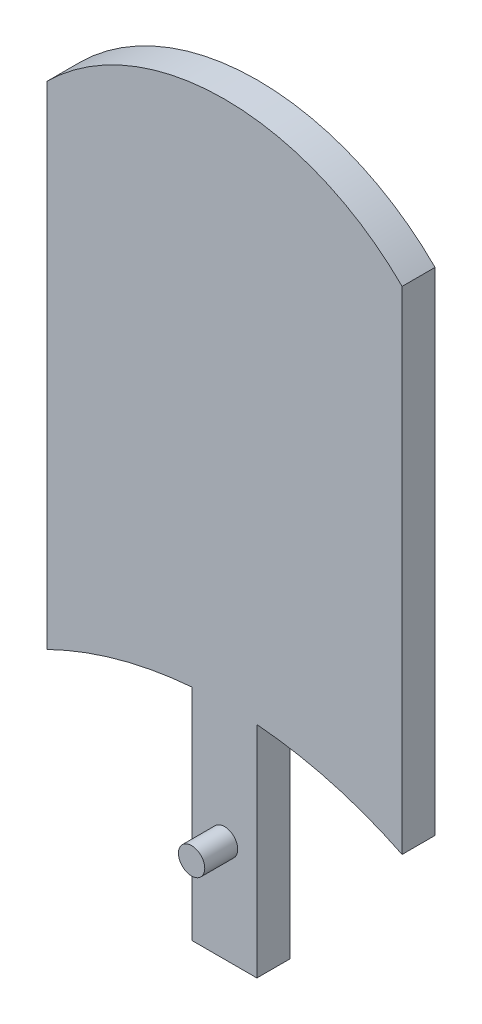
from build123d import *

# Parameters (mm, degrees)
BOSS_EXTRUDE1_DEPTH = 3.175
BOSS_EXTRUDE2_DEPTH = 3.175
SKETCH3_W           = 6.236959702
SKETCH3_H           = 41.352711554
BOSS_EXTRUDE3_DEPTH = 3.175
SKETCH4_R           = 1.27
BOSS_EXTRUDE4_DEPTH = 3.175
BOSS_EXTRUDE5_REACH = 20.766
SKETCH6_W           = 1.202138058
SKETCH6_H           = 43.066281197
CUT_EXTRUDE1_REACH  = 11.525


with BuildPart() as part:
    # Sketch1 → Boss-Extrude1 (new body)
    with BuildSketch(Plane.XY):
        with BuildLine():
            Line((-17.114253333, -23.707583903), (-17.114253333, 23.707583903))
            ThreePointArc((-17.114253333, 23.707583903), (0, 30.782200079), (17.114253333, 23.707583903))
            Line((17.114253333, 23.707583903), (17.114253333, -23.707583903))
            ThreePointArc((17.114253333, -23.707583903), (0, -19.732802645), (-17.114253333, -23.707583903))
        make_face()
    extrude(amount=BOSS_EXTRUDE1_DEPTH)

    # Sketch2 → Boss-Extrude2 (add)
    with BuildSketch(Plane(origin=(0, 0, 0), x_dir=(-1, 0, 0), z_dir=(0, 0, -1))):
        with BuildLine():
            Line((-1.65128862, -19.767928257), (-1.65128862, 22.268343179))
            Line((-1.65128862, 22.268343179), (-1.65128862, 23.29835294))
            Line((-1.65128862, 23.29835294), (-2.853426735, 23.29835294))
            Line((-2.853426735, 23.29835294), (-2.853426735, -19.837781624))
            ThreePointArc((-2.853426735, -19.837781624), (-2.25262846, -19.798194915), (-1.65128862, -19.767928257))
        make_face()
        with BuildLine():
            Line((1.65128862, 23.29835294), (1.65128862, 22.268343179))
            Line((1.65128862, 22.268343179), (1.65128862, -19.767928257))
            ThreePointArc((1.65128862, -19.767928257), (2.25262846, -19.798194915), (2.853426735, -19.837781624))
            Line((2.853426735, -19.837781624), (2.853426735, 23.29835294))
            Line((2.853426735, 23.29835294), (1.65128862, 23.29835294))
        make_face()
    extrude(amount=BOSS_EXTRUDE2_DEPTH)

    # Sketch3 → Boss-Extrude3 (add)
    with BuildSketch(Plane.XY.offset(3.175)):
        with Locations((0, -20.33746726)):
            Rectangle(SKETCH3_W, SKETCH3_H)
    extrude(amount=-BOSS_EXTRUDE3_DEPTH)

    # Sketch4 → Boss-Extrude4 (add)
    with BuildSketch(Plane.XY.offset(3.175)):
        with Locations((0, -31.201683403)):
            Circle(SKETCH4_R)
    extrude(amount=BOSS_EXTRUDE4_DEPTH)

    # Sketch6 → Boss-Extrude5 (add, up to next)
    with BuildSketch(Plane.ZY.offset(-1.65128862), mode=Mode.PRIVATE) as boss_extrude5_sk1:
        with Locations((-2.573930971, 1.765212341)):
            Rectangle(SKETCH6_W, SKETCH6_H)
    boss_extrude5_tool1 = extrude(boss_extrude5_sk1.sketch, amount=BOSS_EXTRUDE5_REACH, mode=Mode.PRIVATE) - part.part
    add(boss_extrude5_tool1.solids().sort_by_distance((1.651289, 1.765212, -2.573931))[0])

    # Sketch8 → Cut-Extrude1 (cut, up to next)
    with BuildSketch(Plane(origin=(0, 0, -3.175), x_dir=(-1, 0, 0), z_dir=(0, 0, -1)), mode=Mode.PRIVATE) as cut_extrude1_sk1:
        Polygon((0, 23.29835294), (-0.889, 23.29835294), (-0.889, -19.767928257), (0.889, -19.767928257), (0.889, 23.29835294), align=None)
    cut_extrude1_tool1 = extrude(cut_extrude1_sk1.sketch, amount=-CUT_EXTRUDE1_REACH, mode=Mode.PRIVATE) & part.part
    add(cut_extrude1_tool1.solids().sort_by_distance((0, 1.765212, -3.175))[0], mode=Mode.SUBTRACT)


solid = part.part
